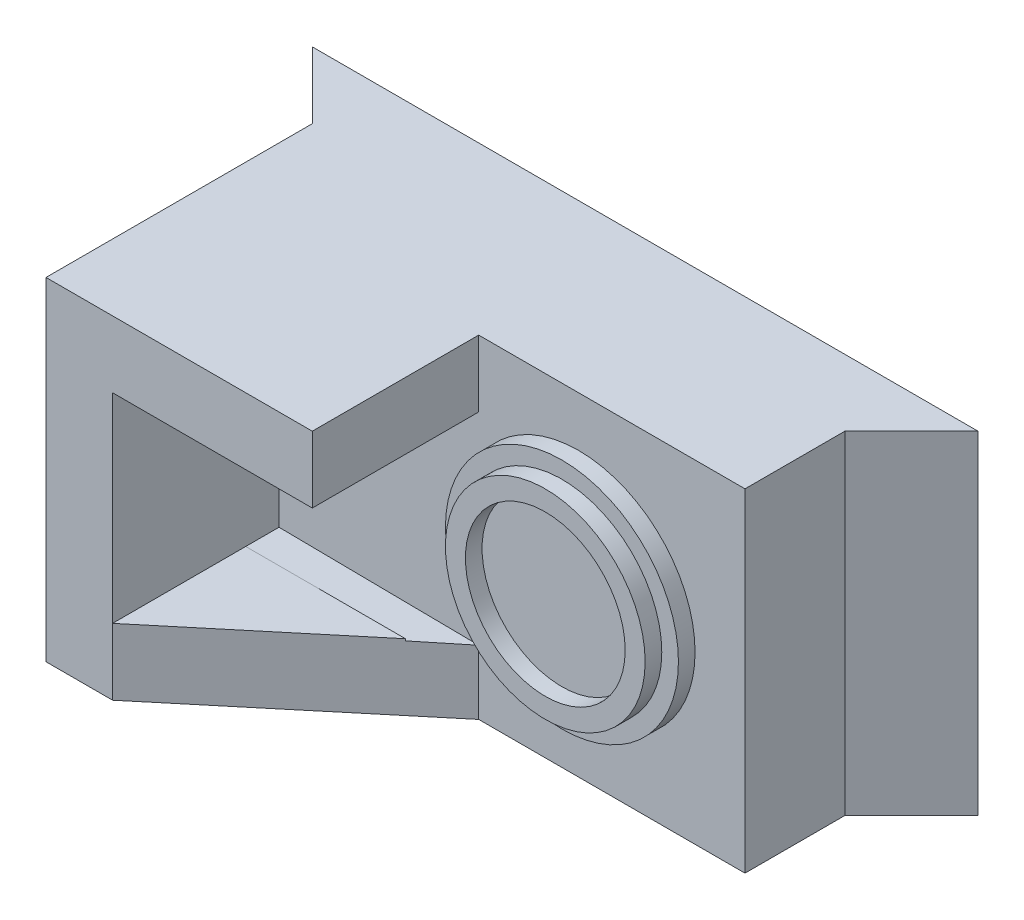
from build123d import *

# Parameters (mm, degrees)
ESQUISSE2_W              = 100
ESQUISSE2_H              = 50
BOSS_EXTRU_1_DEPTH       = 50
ENL_V_MAT_EXTRU_2_DEPTH  = 51
ESQUISSE7_W              = 40
ESQUISSE7_H              = 50
ENL_V_MAT_EXTRU_3_DEPTH  = 20
ESQUISSE8_W              = 30
ESQUISSE8_H              = 30
ENL_V_MAT_EXTRU_4_DEPTH  = 20
ENL_V_MAT_EXTRU_7_DEPTH  = 2.5
ENL_V_MAT_EXTRU_10_DEPTH = 5
ENL_V_MAT_EXTRU_11_DEPTH = 5
ENL_V_MAT_EXTRU_12_DEPTH = 10
ESQUISSE16_R             = 17.5
ESQUISSE16_R_2           = 15
ENL_V_MAT_EXTRU_13_DEPTH = 2.5
ESQUISSE17_R             = 12
ENL_V_MAT_EXTRU_14_DEPTH = 2.5


with BuildPart() as part:
    # Esquisse2 → Boss.-Extru.1 (new body)
    with BuildSketch(Plane.XY):
        with Locations((19.891640867, -6.114551084)):
            Rectangle(ESQUISSE2_W, ESQUISSE2_H)
    extrude(amount=BOSS_EXTRU_1_DEPTH)

    # Esquisse5 → Enlèv. mat.-Extru.2 (cut, through all)
    with BuildSketch(Plane(origin=(0, -31.114551084, 0), x_dir=(-1, 0, 0), z_dir=(0, -1, 0))):
        Polygon((30.108359133, 0), (20.108359133, -10), (20.108359133, -50), (30.108359133, -50), align=None)
        Polygon((-69.891640867, 0), (-59.891640867, -10), (-59.891640867, -50), (-69.891640867, -50), align=None)
    extrude(amount=-ENL_V_MAT_EXTRU_2_DEPTH, mode=Mode.SUBTRACT)

    # Esquisse7 → Enlèv. mat.-Extru.3 (cut)
    with BuildSketch(Plane.XY.offset(50)):
        with Locations((39.891640867, -6.114551084)):
            Rectangle(ESQUISSE7_W, ESQUISSE7_H)
    extrude(amount=-ENL_V_MAT_EXTRU_3_DEPTH, mode=Mode.SUBTRACT)

    # Esquisse8 → Enlèv. mat.-Extru.4 (cut)
    with BuildSketch(Plane.XY.offset(50)):
        with Locations((4.891640867, -6.114551084)):
            Rectangle(ESQUISSE8_W, ESQUISSE8_H)
    extrude(amount=-ENL_V_MAT_EXTRU_4_DEPTH, mode=Mode.SUBTRACT)

    # Esquisse9 → Enlèv. mat.-Extru.7 (cut)
    with BuildSketch(Plane.XY.offset(30)):
        with BuildLine():
            Line((25.877762678, 8.885448916), (19.891640867, 8.885448916))
            Line((19.891640867, 8.885448916), (-10.108359133, 8.885448916))
            Line((-10.108359133, 8.885448916), (-10.108359133, -20.265562259))
            Line((-10.108359133, -20.265562259), (-10.108359133, -21.114551084))
            Line((-10.108359133, -21.114551084), (19.891640867, -21.114551084))
            Line((19.891640867, -21.114551084), (26.628394236, -21.540787019))
            ThreePointArc((26.628394236, -21.540787019), (17.396963997, -6.546154144), (25.877762678, 8.885448916))
        make_face()
    extrude(amount=-ENL_V_MAT_EXTRU_7_DEPTH, mode=Mode.SUBTRACT)

    # Esquisse11 → Enlèv. mat.-Extru.10 (cut)
    with BuildSketch(Plane.XY.offset(30)):
        with BuildLine():
            Line((26.628394236, -21.540787019), (19.891640867, -21.114551084))
            Line((19.891640867, -21.114551084), (19.891640867, -31.114551084))
            Line((19.891640867, -31.114551084), (59.891640867, -31.114551084))
            Line((59.891640867, -31.114551084), (59.891640867, 18.885448916))
            Line((59.891640867, 18.885448916), (19.891640867, 18.885448916))
            Line((19.891640867, 18.885448916), (19.891640867, 8.885448916))
            Line((19.891640867, 8.885448916), (25.877762678, 8.885448916))
            ThreePointArc((25.877762678, 8.885448916), (43.508691746, 9.116878073), (52.391640867, -6.114551084))
            ThreePointArc((52.391640867, -6.114551084), (43.881723847, -21.12882456), (26.628394236, -21.540787019))
        make_face()
    extrude(amount=-ENL_V_MAT_EXTRU_10_DEPTH, mode=Mode.SUBTRACT)

    # Esquisse13 → Enlèv. mat.-Extru.11 (cut)
    with BuildSketch(Plane.XY.offset(30)):
        with BuildLine():
            ThreePointArc((26.628394236, -21.540787019), (17.396963997, -6.546154144), (25.877762678, 8.885448916))
            Line((25.877762678, 8.885448916), (-10.108359133, 8.885448916))
            Line((-10.108359133, 8.885448916), (-10.108359133, -21.114551084))
            Line((-10.108359133, -21.114551084), (26.628394236, -21.540787019))
        make_face()
    extrude(amount=-ENL_V_MAT_EXTRU_11_DEPTH, mode=Mode.SUBTRACT)

    # Esquisse15 → Enlèv. mat.-Extru.12 (cut)
    with BuildSketch(Plane(origin=(0, -31.114551084, 0), x_dir=(-1, 0, 0), z_dir=(0, -1, 0))):
        Polygon((10.108359133, -50), (-19.891640867, -25), (-19.891640867, -50), align=None)
    extrude(amount=-ENL_V_MAT_EXTRU_12_DEPTH, mode=Mode.SUBTRACT)

    # Esquisse16 → Enlèv. mat.-Extru.13 (cut)
    with BuildSketch(Plane.XY.offset(30)):
        with Locations((34.891640867, -6.114551084)):
            Circle(ESQUISSE16_R)
        with Locations((34.891640867, -6.114551084)):
            Circle(ESQUISSE16_R_2, mode=Mode.SUBTRACT)
    extrude(amount=-ENL_V_MAT_EXTRU_13_DEPTH, mode=Mode.SUBTRACT)

    # Esquisse17 → Enlèv. mat.-Extru.14 (cut)
    with BuildSketch(Plane.XY.offset(30)):
        with Locations((34.891640867, -6.114551084)):
            Circle(ESQUISSE17_R)
    extrude(amount=-ENL_V_MAT_EXTRU_14_DEPTH, mode=Mode.SUBTRACT)


solid = part.part
